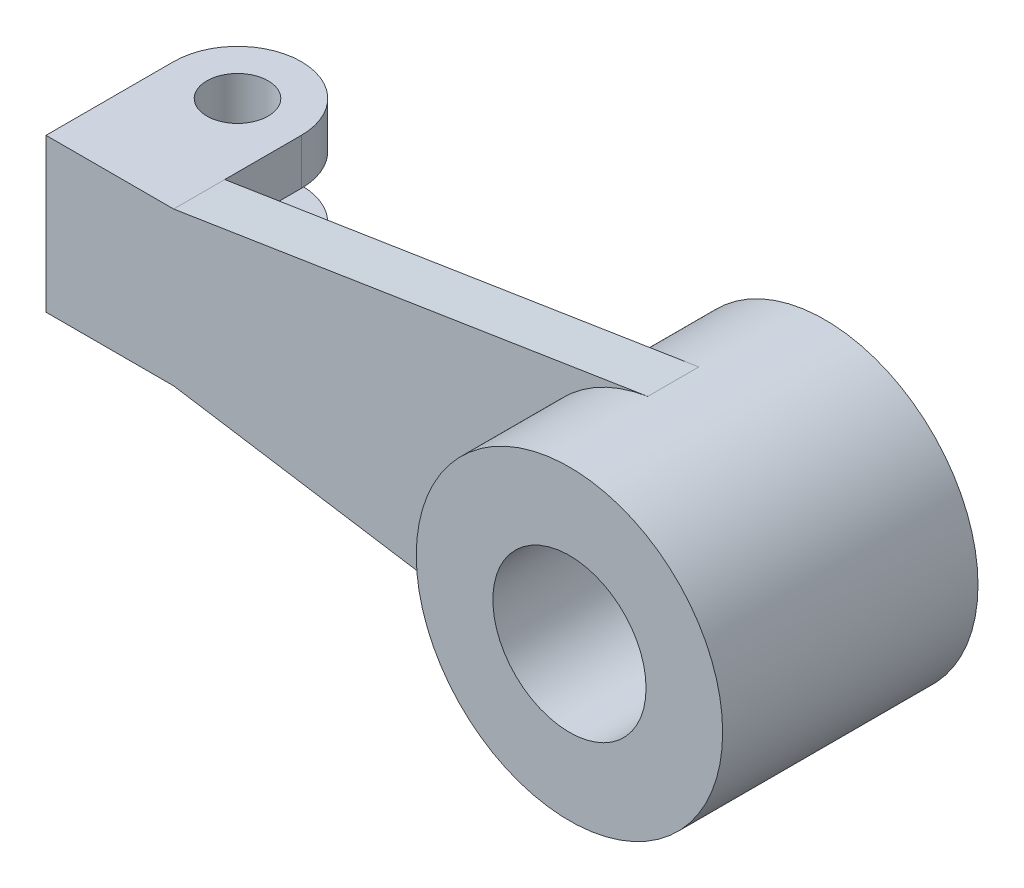
from build123d import *

# Parameters (mm, degrees)
SKETCH1_R           = 30
SKETCH1_R_2         = 15
BOSS_EXTRUDE1_DEPTH = 25
BOSS_EXTRUDE2_DEPTH = 5
SKETCH3_R           = 6
BOSS_EXTRUDE3_DEPTH = 9


with BuildPart() as part:
    # Sketch1 → Boss-Extrude1 (new body, symmetric)
    with BuildSketch(Plane.XY):
        Circle(SKETCH1_R)
        Circle(SKETCH1_R_2, mode=Mode.SUBTRACT)
    extrude(amount=BOSS_EXTRUDE1_DEPTH, both=True)

    # Sketch2 → Boss-Extrude2 (add, symmetric)
    with BuildSketch(Plane.XY):
        with BuildLine():
            Line((-4.671688756, 29.634023084), (-97.5, 15))
            Line((-97.5, 15), (-122.5, 15))
            Line((-122.5, 15), (-122.5, -15))
            Line((-122.5, -15), (-97.5, -15))
            Line((-97.5, -15), (-4.671688756, -29.634023084))
            ThreePointArc((-4.671688756, -29.634023084), (-30, 0), (-4.671688756, 29.634023084))
        make_face()
    boss_extrude2 = extrude(amount=BOSS_EXTRUDE2_DEPTH, both=True)

    # Sketch3 → Boss-Extrude3 (add)
    with BuildSketch(Plane(origin=(0, 15, 0), x_dir=(1, 0, 0), z_dir=(0, 1, 0))):
        with BuildLine():
            Line((-97.5, 5), (-122.5, 5))
            Line((-122.5, 5), (-122.5, 20))
            ThreePointArc((-122.5, 20), (-110, 32.5), (-97.5, 20))
            Line((-97.5, 20), (-97.5, 5))
        make_face()
        with Locations(Location((-110, 20, 0), (0, 0, 180))):  # turned: the seam where the file's is
            Circle(SKETCH3_R, mode=Mode.SUBTRACT)
    boss_extrude3 = extrude(amount=-BOSS_EXTRUDE3_DEPTH)

    # Mirror1: Boss-Extrude2, Boss-Extrude3 across plane
    add(boss_extrude2.mirror(Plane.ZX))
    add(boss_extrude3.mirror(Plane.ZX))


solid = part.part
